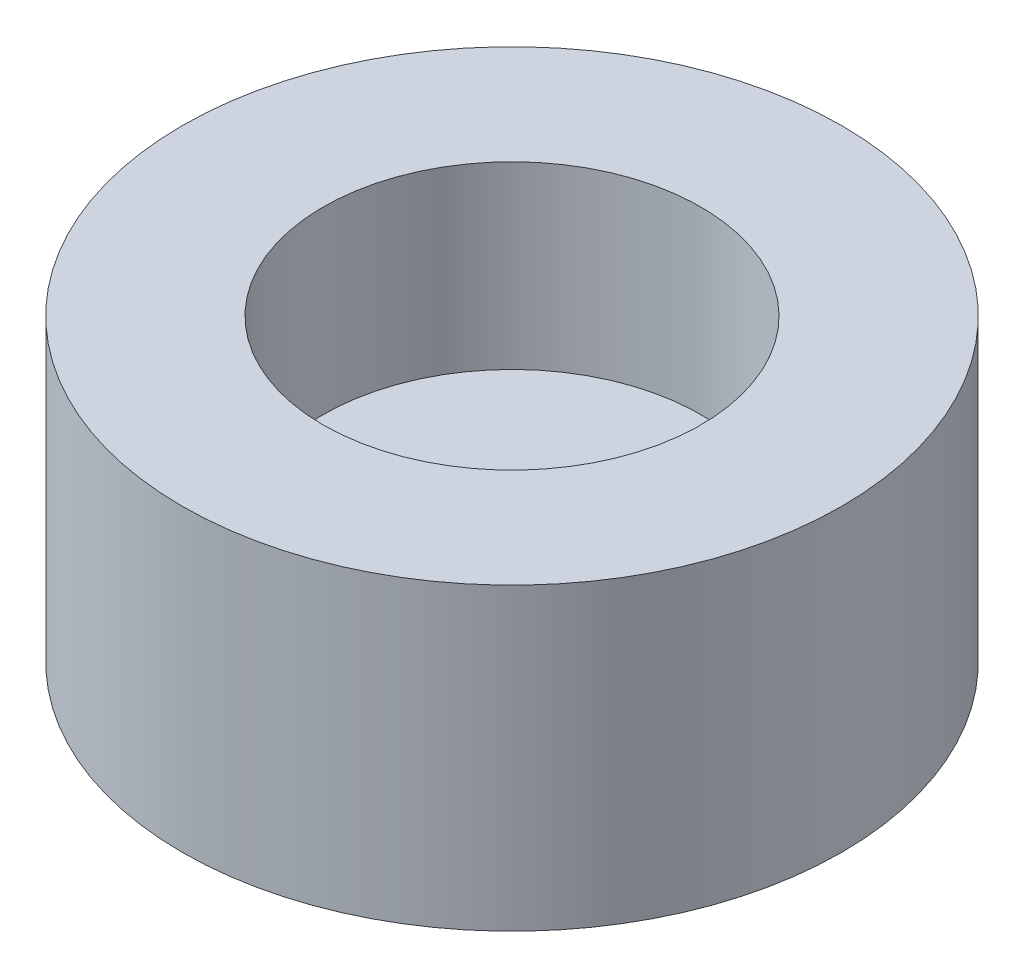
from build123d import *

# Parameters (mm, degrees)
SKETCH2_R           = 11
BOSS_EXTRUDE1_DEPTH = 10
CUT_EXTRUDE1_START  = 10
SKETCH2_3_R         = 6.3
CUT_EXTRUDE1_DEPTH  = 6


with BuildPart() as part:
    # Sketch2 → Boss-Extrude1 (new body)
    with BuildSketch(Plane(origin=(0, 0, 0), x_dir=(1, 0, 0), z_dir=(0, 1, 0))):
        Circle(SKETCH2_R)
    extrude(amount=BOSS_EXTRUDE1_DEPTH)

    # Sketch2_3 → Cut-Extrude1 (cut)
    with BuildSketch(Plane(origin=(0, 0, 0), x_dir=(1, 0, 0), z_dir=(0, 1, 0)).offset(CUT_EXTRUDE1_START)):
        Circle(SKETCH2_3_R)
    extrude(amount=-CUT_EXTRUDE1_DEPTH, mode=Mode.SUBTRACT)


solid = part.part
